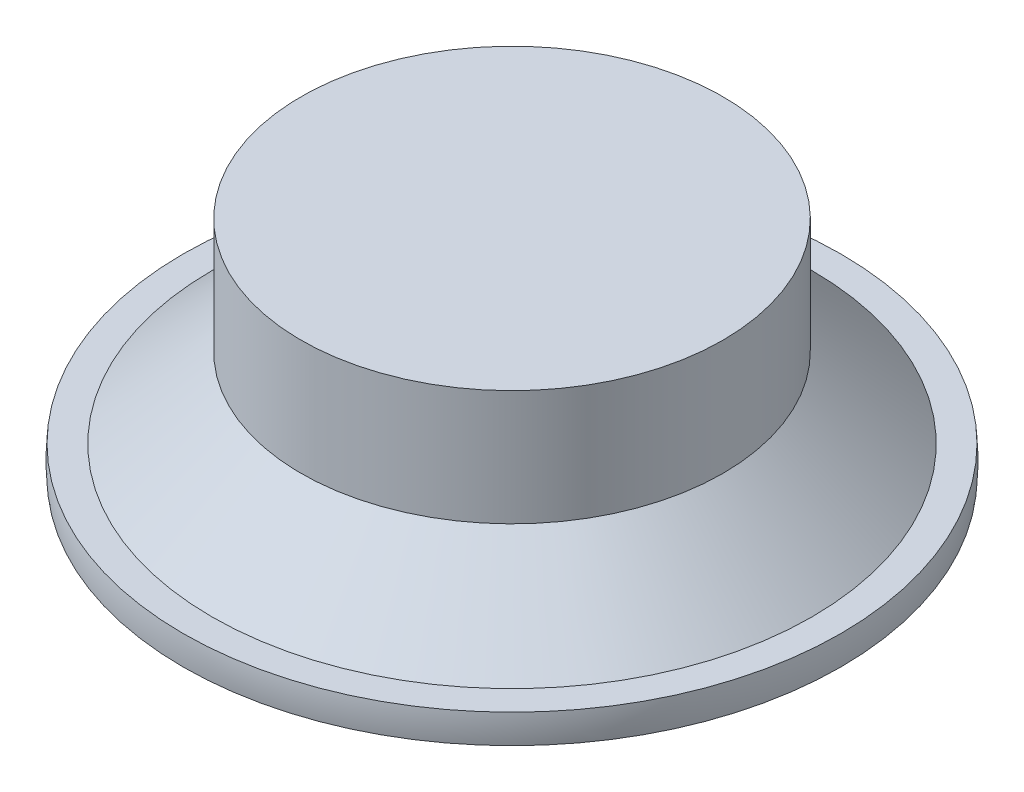
from build123d import *


with BuildPart() as part:
    # Esquisse1 → Révolution2 (revolve)
    with BuildSketch(Plane.XY):
        with BuildLine():
            Line((0, 27.2), (0, 21.409433365))
            Line((0, 21.409433365), (0, 0))
            Line((0, 0), (39.905430081, 0))
            ThreePointArc((39.905430081, 0), (40, 1.76), (39.905430081, 3.52))
            Line((39.905430081, 3.52), (36.405430081, 3.52))
            Line((36.405430081, 3.52), (25.6, 13.2))
            Line((25.6, 13.2), (25.6, 27.2))
            Line((25.6, 27.2), (0, 27.2))
        make_face()
    revolve(axis=Axis((0, 0, 0), (0, 1, 0)))


solid = part.part
